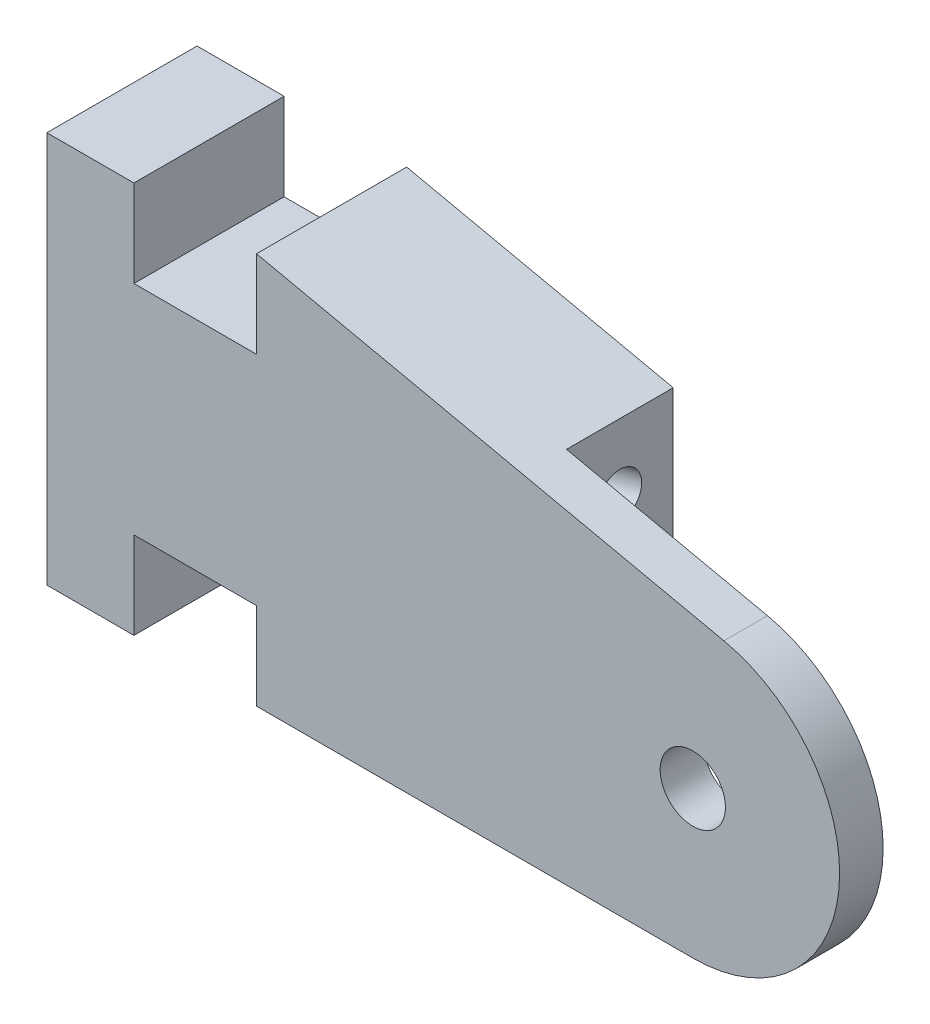
from build123d import *

# Parameters (mm, degrees)
SKETCH1_R           = 1.5
BOSS_EXTRUDE1_DEPTH = 6.9
CUT_EXTRUDE2_DEPTH  = 4.9
SKETCH5_R           = 1
CUT_EXTRUDE3_DEPTH  = 7
SKETCH8_R           = 1
CUT_EXTRUDE5_DEPTH  = 17


with BuildPart() as part:
    # Sketch1 → Boss-Extrude1 (new body)
    with BuildSketch(Plane.XY):
        with BuildLine():
            Line((0, 0), (0, 18.000341084))
            Line((0, 18.000341084), (4, 18.000341084))
            Line((4, 18.000341084), (4, 14.000341084))
            Line((4, 14.000341084), (9.631516349, 14.000341084))
            Line((9.631516349, 14.000341084), (9.631516349, 18.000341084))
            Line((9.631516349, 18.000341084), (31.10792826, 13.336453737))
            ThreePointArc((31.10792826, 13.336453737), (36.383041872, 6.025227564), (29.676516349, 0))
            Line((29.676516349, 0), (9.631516349, 0))
            Line((9.631516349, 0), (9.631516349, 4))
            Line((9.631516349, 4), (4, 4))
            Line((4, 4), (4, 0))
            Line((4, 0), (0, 0))
        make_face()
        with Locations((29.676516349, 6.745044143)):
            Circle(SKETCH1_R, mode=Mode.SUBTRACT)
    extrude(amount=BOSS_EXTRUDE1_DEPTH)

    # Sketch4 → Cut-Extrude2 (cut)
    with BuildSketch(Plane.XY):
        with BuildLine():
            Line((21.876472206, 0), (21.876472206, 15.341186709))
            Line((21.876472206, 15.341186709), (31.10792826, 13.336453737))
            ThreePointArc((31.10792826, 13.336453737), (36.383041872, 6.025227564), (29.676516349, 0))
            Line((29.676516349, 0), (21.876472206, 0))
        make_face()
    extrude(amount=CUT_EXTRUDE2_DEPTH, mode=Mode.SUBTRACT)

    # Sketch5 → Cut-Extrude3 (cut)
    with BuildSketch(Plane.ZY):
        with Locations((2.45, 8)):
            Circle(SKETCH5_R)
    extrude(amount=-CUT_EXTRUDE3_DEPTH, mode=Mode.SUBTRACT)

    # Sketch8 → Cut-Extrude5 (cut)
    with BuildSketch(Plane(origin=(24.246323118, 6.496782699, 0), x_dir=(0, 0, -1), z_dir=(0.965925826, 0.258819045, 0))):
        with Locations((-2.45, 6.201190468)):
            Circle(SKETCH8_R)
    extrude(amount=-CUT_EXTRUDE5_DEPTH, mode=Mode.SUBTRACT)


solid = part.part
